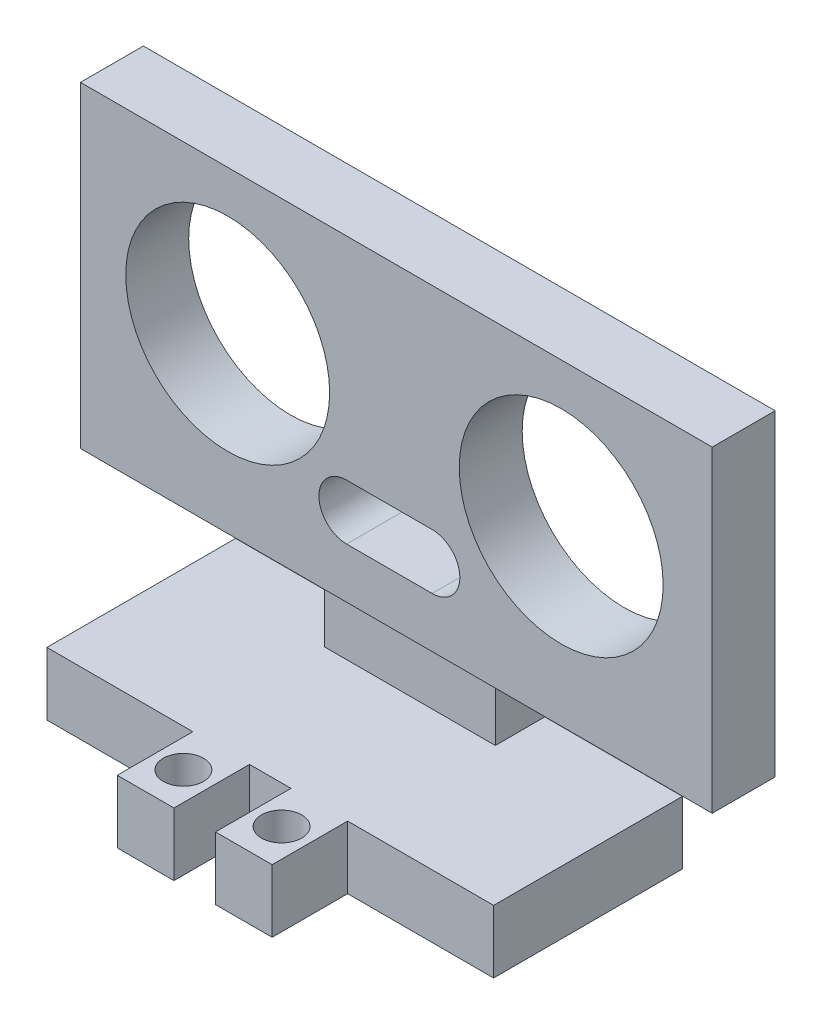
from build123d import *

# Parameters (mm, degrees)
BOSS_EXTRUDE7_DEPTH = 5
SKETCH5_W           = 13.567085075
SKETCH5_H           = 3.932792286
BOSS_EXTRUDE8_DEPTH = 5
SKETCH6_W           = 50.2
SKETCH6_H           = 5
BOSS_EXTRUDE9_DEPTH = 25.2
SKETCH7_R           = 8.1
CUT_EXTRUDE1_DEPTH  = 10
CUT_EXTRUDE2_DEPTH  = 10
SKETCH9_R           = 1.6
CUT_EXTRUDE4_DEPTH  = 10


with BuildPart() as part:
    # Sketch1 → Boss-Extrude7 (new body)
    with BuildSketch(Plane(origin=(0, 0, 0), x_dir=(1, 0, 0), z_dir=(0, 1, 0))):
        Polygon((12.769214264, 6.275388257), (24.369214264, 6.275388257), (24.369214264, 0.275388257), (28.869214264, 0.275388257), (28.869214264, 6.275388257), (32.169214264, 6.275388257), (32.169214264, 0.275388257), (36.669214264, 0.275388257), (36.669214264, 6.275388257), (48.269214264, 6.275388257), (48.269214264, 21.275388257), (12.769214264, 21.275388257), align=None)
    extrude(amount=BOSS_EXTRUDE7_DEPTH)

    # Sketch5 → Boss-Extrude8 (add)
    with BuildSketch(Plane(origin=(0, 5, 0), x_dir=(1, 0, 0), z_dir=(0, 1, 0))):
        with Locations((30.552756802, 19.308992114)):
            Rectangle(SKETCH5_W, SKETCH5_H)
    extrude(amount=BOSS_EXTRUDE8_DEPTH)

    # Sketch6 → Boss-Extrude9 (add)
    with BuildSketch(Plane(origin=(1.124638213, 10, 0), x_dir=(1, 0, 0), z_dir=(0, 1, 0))):
        with Locations((29.394576051, 18.794771585)):
            Rectangle(SKETCH6_W, SKETCH6_H)
    extrude(amount=BOSS_EXTRUDE9_DEPTH)

    # Sketch7 → Cut-Extrude1 (cut)
    with BuildSketch(Plane.XY.offset(-16.294771585)):
        with Locations((43.619214264, 23.75)):
            Circle(SKETCH7_R)
        with Locations((17.119214264, 23.75)):
            Circle(SKETCH7_R)
    extrude(amount=-CUT_EXTRUDE1_DEPTH, mode=Mode.SUBTRACT)

    # Sketch7_3 → Cut-Extrude2 (cut)
    with BuildSketch(Plane.XY.offset(-16.294771585)):
        with BuildLine():
            Line((33.366421185, 18.4), (26.566421185, 18.4))
            ThreePointArc((26.566421185, 18.4), (24.366421185, 16.2), (26.566421185, 14))
            Line((26.566421185, 14), (33.366421185, 14))
            ThreePointArc((33.366421185, 14), (35.566421185, 16.2), (33.366421185, 18.4))
        make_face()
    extrude(amount=-CUT_EXTRUDE2_DEPTH, mode=Mode.SUBTRACT)

    # Sketch9 → Cut-Extrude4 (cut)
    with BuildSketch(Plane(origin=(0, 5, 0), x_dir=(1, 0, 0), z_dir=(0, 1, 0))):
        with Locations((26.619214264, 3.275388257)):
            Circle(SKETCH9_R)
        with Locations((34.419214264, 3.275388257)):
            Circle(SKETCH9_R)
    extrude(amount=-CUT_EXTRUDE4_DEPTH, mode=Mode.SUBTRACT)


solid = part.part
